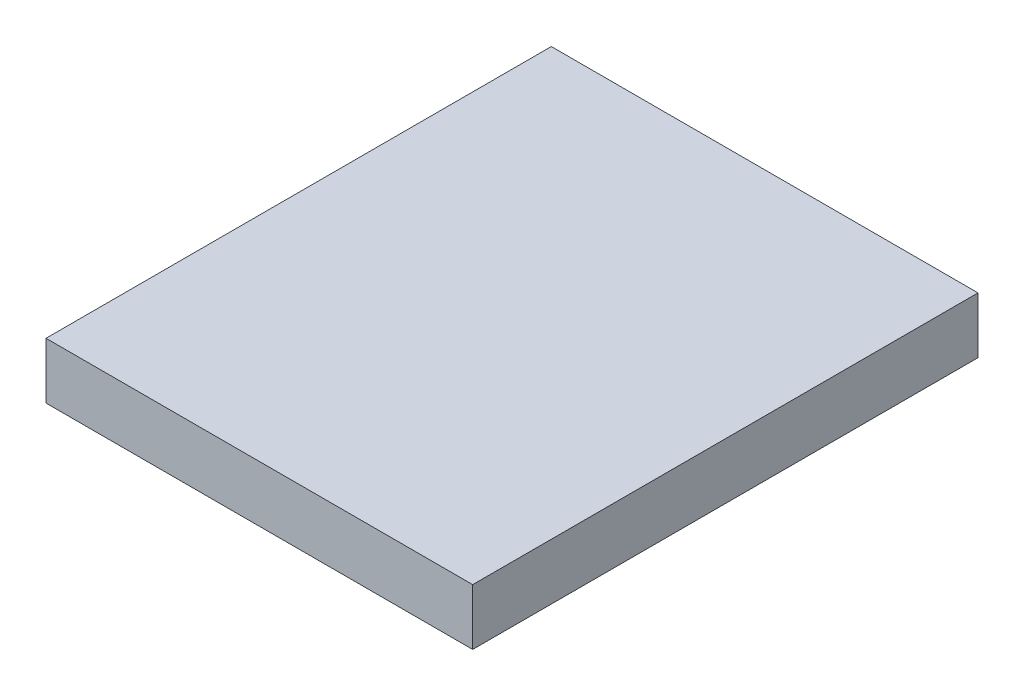
from build123d import *

# Parameters (mm, degrees)
ESBO_O1_W                = 76
ESBO_O1_H                = 90
RESSALTO_EXTRUS_O1_DEPTH = 10


with BuildPart() as part:
    # Esboço1 → Ressalto-extrusão1 (new body)
    with BuildSketch(Plane(origin=(0, 0, 0), x_dir=(1, 0, 0), z_dir=(0, 1, 0))):
        with Locations((-6.400866803, 15.221707086)):
            Rectangle(ESBO_O1_W, ESBO_O1_H)
    extrude(amount=RESSALTO_EXTRUS_O1_DEPTH)


solid = part.part
